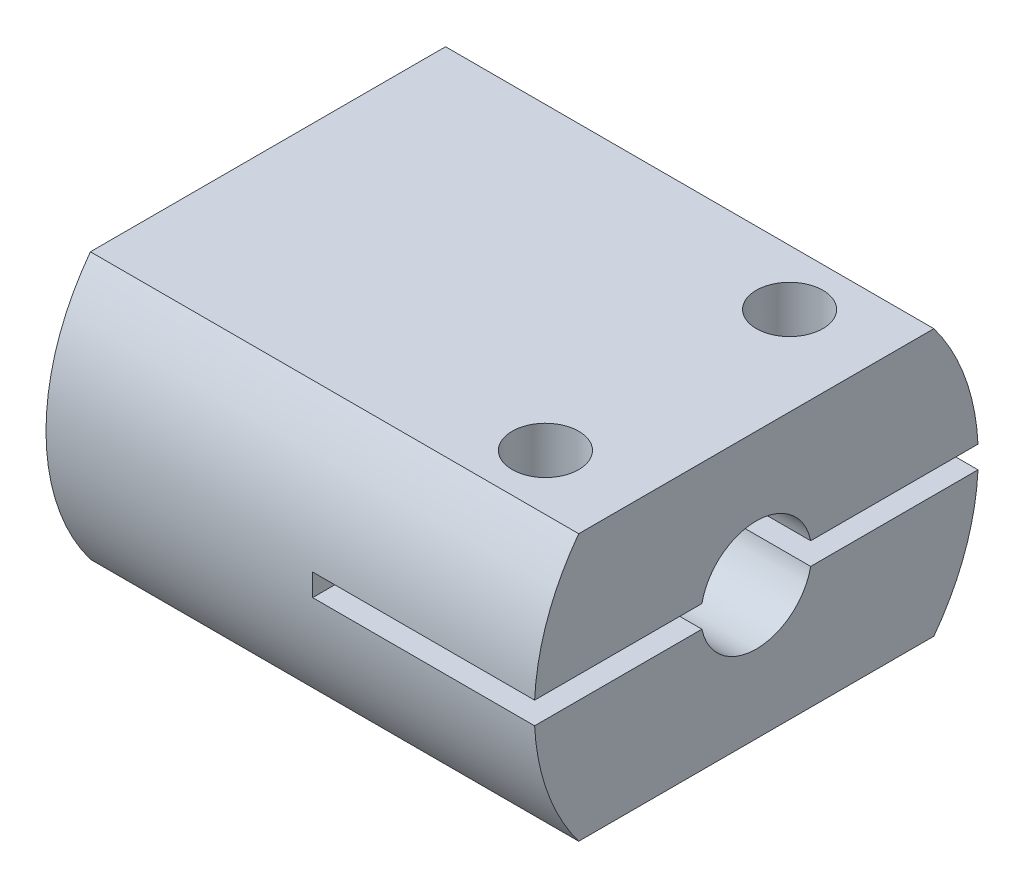
from build123d import *

# Parameters (mm, degrees)
SKETCH1_R           = 10
BOSS_EXTRUDE1_DEPTH = 22
CUT_EXTRUDE1_DEPTH  = 12
CUT_EXTRUDE2_DEPTH  = 10
SKETCH5_W           = 16
SKETCH5_H           = 4
CUT_EXTRUDE4_DEPTH  = 23
SKETCH4_R           = 1.5
CUT_EXTRUDE3_DEPTH  = 13


with BuildPart() as part:
    # Sketch1 → Boss-Extrude1 (new body)
    with BuildSketch(Plane(origin=(0, 0, 0), x_dir=(0, 0, -1), z_dir=(1, 0, 0))):
        Circle(SKETCH1_R)
    extrude(amount=BOSS_EXTRUDE1_DEPTH)

    # Sketch2 → Cut-Extrude1 (cut)
    with BuildSketch(Plane.ZY):
        with BuildLine():
            Line((-2, 3.464101615), (2, 3.464101615))
            ThreePointArc((2, 3.464101615), (0, -4), (-2, 3.464101615))
        make_face()
    extrude(amount=-CUT_EXTRUDE1_DEPTH, mode=Mode.SUBTRACT)

    # Sketch3 → Cut-Extrude2 (cut)
    with BuildSketch(Plane(origin=(22, 0, 0), x_dir=(0, 0, -1), z_dir=(1, 0, 0))):
        with BuildLine():
            Line((-2.449489743, 0.5), (-9.987492178, 0.5))
            ThreePointArc((-9.987492178, 0.5), (-9.996872555, 0.250078211), (-10, 0))
            ThreePointArc((-10, 0), (-9.996872555, -0.250078211), (-9.987492178, -0.5))
            Line((-9.987492178, -0.5), (-2.449489743, -0.5))
            ThreePointArc((-2.449489743, -0.5), (-2.5, 0), (-2.449489743, 0.5))
        make_face()
        with BuildLine():
            ThreePointArc((10, 0), (9.996872555, 0.250078211), (9.987492178, 0.5))
            Line((9.987492178, 0.5), (2.449489743, 0.5))
            ThreePointArc((2.449489743, 0.5), (2.487340383, 0.251272405), (2.5, 0))
            ThreePointArc((2.5, 0), (2.487340383, -0.251272405), (2.449489743, -0.5))
            Line((2.449489743, -0.5), (9.987492178, -0.5))
            ThreePointArc((9.987492178, -0.5), (9.996872555, -0.250078211), (10, 0))
        make_face()
        with BuildLine():
            Line((2.449489743, -0.5), (-2.449489743, -0.5))
            ThreePointArc((-2.449489743, -0.5), (0, -2.5), (2.449489743, -0.5))
        make_face()
        with BuildLine():
            Line((2.449489743, 0.5), (-2.449489743, 0.5))
            ThreePointArc((-2.449489743, 0.5), (-2.5, 0), (-2.449489743, -0.5))
            Line((-2.449489743, -0.5), (2.449489743, -0.5))
            ThreePointArc((2.449489743, -0.5), (2.487340383, -0.251272405), (2.5, 0))
            ThreePointArc((2.5, 0), (2.487340383, 0.251272405), (2.449489743, 0.5))
        make_face()
        with BuildLine():
            ThreePointArc((2.449489743, 0.5), (0, 2.5), (-2.449489743, 0.5))
            Line((-2.449489743, 0.5), (2.449489743, 0.5))
        make_face()
    extrude(amount=-CUT_EXTRUDE2_DEPTH, mode=Mode.SUBTRACT)

    # Sketch5 → Cut-Extrude4 (cut, through all)
    with BuildSketch(Plane(origin=(22, 0, 0), x_dir=(0, 0, -1), z_dir=(1, 0, 0))):
        with Locations((0, 8)):
            Rectangle(SKETCH5_W, SKETCH5_H)
        with Locations((0, -8)):
            Rectangle(SKETCH5_W, SKETCH5_H)
    extrude(amount=-CUT_EXTRUDE4_DEPTH, mode=Mode.SUBTRACT)

    # Sketch4 → Cut-Extrude3 (cut, through all)
    with BuildSketch(Plane(origin=(0, 6, 0), x_dir=(1, 0, 0), z_dir=(0, 1, 0))):
        with Locations((18, 5.5)):
            Circle(SKETCH4_R)
        with Locations((18, -5.5)):
            Circle(SKETCH4_R)
    extrude(amount=-CUT_EXTRUDE3_DEPTH, mode=Mode.SUBTRACT)


solid = part.part
